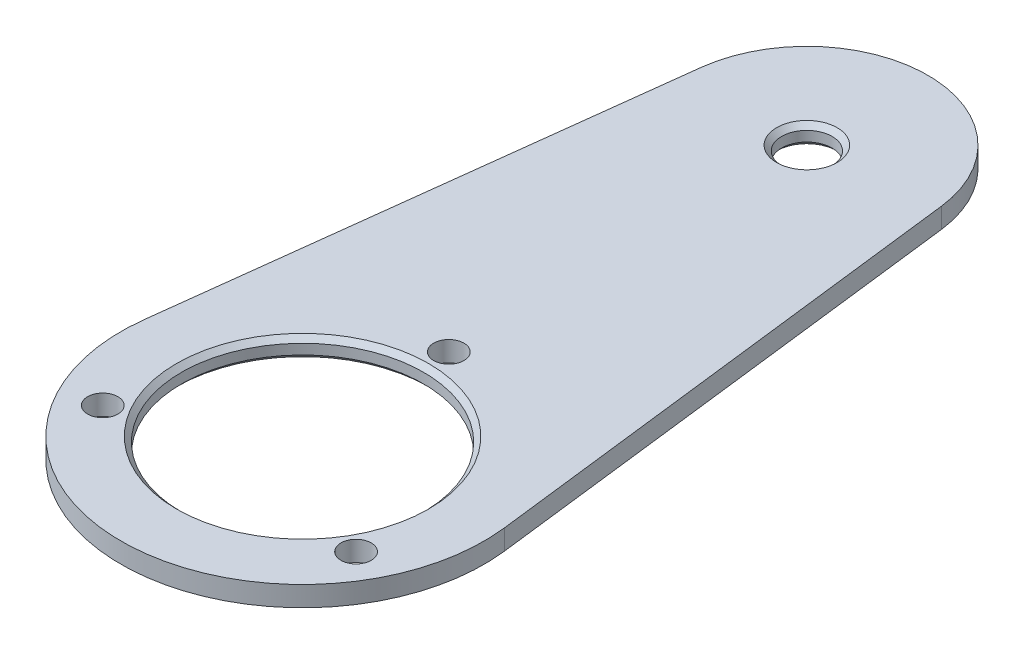
from build123d import *

# Parameters (mm, degrees)
ESQUISSE1_R      = 12
ESQUISSE1_R_2    = 2.5
ESQUISSE1_R_3    = 1.5
EXTRUSION1_DEPTH = 2
CHANFREIN1_SIZE  = 0.5


with BuildPart() as part:
    # Esquisse1 → Extrusion1 (new body)
    with BuildSketch(Plane(origin=(0, 0, 0), x_dir=(1, 0, 0), z_dir=(0, 1, 0))):
        with BuildLine():
            Line((-11.9132867, 51.44), (-17.86993005, 2.16))
            ThreePointArc((-17.86993005, 2.16), (0, -18), (17.86993005, 2.16))
            Line((17.86993005, 2.16), (11.9132867, 51.44))
            ThreePointArc((11.9132867, 51.44), (0, 62), (-11.9132867, 51.44))
        make_face()
        Circle(ESQUISSE1_R, mode=Mode.SUBTRACT)
        with Locations((0, 50)):
            Circle(ESQUISSE1_R_2, mode=Mode.SUBTRACT)
        with Locations((-12.557368355, -7.25)):
            Circle(ESQUISSE1_R_3, mode=Mode.SUBTRACT)
        with Locations((12.557368355, -7.25)):
            Circle(ESQUISSE1_R_3, mode=Mode.SUBTRACT)
        with Locations((0, 14.5)):
            Circle(ESQUISSE1_R_3, mode=Mode.SUBTRACT)
    extrude(amount=EXTRUSION1_DEPTH)

    # Chanfrein1
    chanfrein1_edges = [part.edges().sort_by_distance(p)[0] for p in [
        (-12, 0, 0),
        (-12, 2, 0),
        (-2.5, 0, -50),
        (-2.5, 2, -50),
    ]]
    chamfer(chanfrein1_edges, length=CHANFREIN1_SIZE)


solid = part.part
